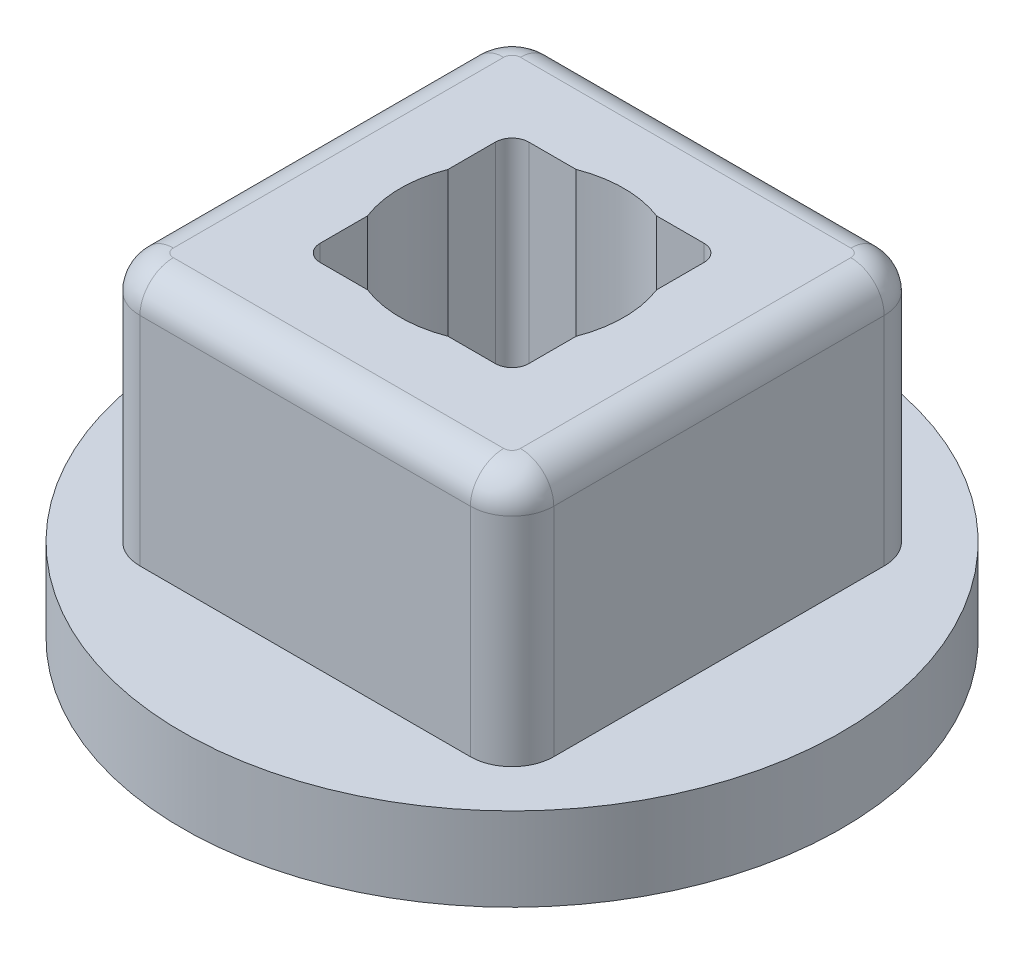
from build123d import *

# Parameters (mm, degrees)
SKETCH1_W           = 5.0165
SKETCH1_H           = 1.27
SKETCH2_W           = 6.2992
SKETCH2_H           = 6.2992
BOSS_EXTRUDE1_DEPTH = 3.81
SKETCH3_W           = 3.175
SKETCH3_H           = 3.175
CUT_EXTRUDE1_DEPTH  = 6.08
FILLET1_R           = 0.635
FILLET2_R           = 0.254
FILLET3_R           = 0.508
SKETCH4_R           = 1.7018
CUT_EXTRUDE2_DEPTH  = 51.054


with BuildPart() as part:
    # Sketch1 → Revolve1 (revolve)
    with BuildSketch(Plane.XY):
        with Locations((2.50825, 0.635)):
            Rectangle(SKETCH1_W, SKETCH1_H)
    revolve(axis=Axis((0, 1.27, 0), (0, -1, 0)))

    # Sketch2 → Boss-Extrude1 (add)
    with BuildSketch(Plane(origin=(0, 1.27, 0), x_dir=(-1, 0, 0), z_dir=(0, 1, 0))):
        Rectangle(SKETCH2_W, SKETCH2_H)
    extrude(amount=BOSS_EXTRUDE1_DEPTH)

    # Sketch3 → Cut-Extrude1 (cut, through all)
    with BuildSketch(Plane.XZ):
        Rectangle(SKETCH3_W, SKETCH3_H)
    extrude(amount=-CUT_EXTRUDE1_DEPTH, mode=Mode.SUBTRACT)

    # Fillet1
    fillet1_edges = [part.edges().sort_by_distance(p)[0] for p in [
        (3.1496, 3.175, 3.1496),
        (3.1496, 3.175, -3.1496),
        (-3.1496, 3.175, -3.1496),
        (-3.1496, 3.175, 3.1496),
    ]]
    fillet(fillet1_edges, radius=FILLET1_R)

    # Fillet2
    fillet2_edges = [part.edges().sort_by_distance(p)[0] for p in [
        (-1.5875, 2.54, -1.5875),
        (-1.5875, 2.54, 1.5875),
        (1.5875, 2.54, 1.5875),
        (1.5875, 2.54, -1.5875),
    ]]
    fillet(fillet2_edges, radius=FILLET2_R)

    # Fillet3
    fillet3_edges = [part.edges().sort_by_distance(p)[0] for p in [
        (0, 5.08, 3.1496),
        (-3.1496, 5.08, 0),
        (3.1496, 5.08, 0),
        (0, 5.08, -3.1496),
        (2.963612806, 5.08, -2.963612806),
        (-2.963612806, 5.08, -2.963612806),
        (2.963612806, 5.08, 2.963612806),
        (-2.963612806, 5.08, 2.963612806),
    ]]
    fillet(fillet3_edges, radius=FILLET3_R)

    # Sketch4 → Cut-Extrude2 (cut)
    with BuildSketch(Plane(origin=(0, 5.08, 0), x_dir=(1, 0, 0), z_dir=(0, 1, 0))):
        Circle(SKETCH4_R)
    extrude(amount=-CUT_EXTRUDE2_DEPTH, mode=Mode.SUBTRACT)


solid = part.part
